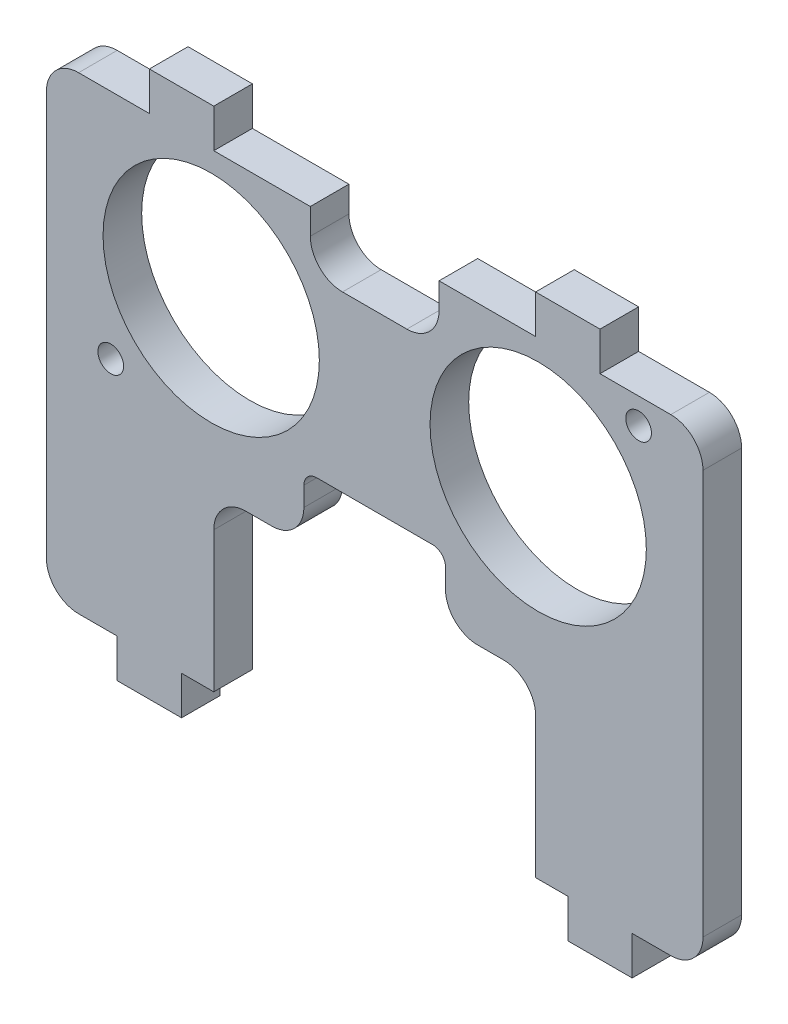
from build123d import *

# Parameters (mm, degrees)
SKETCH1_R           = 1
SKETCH1_R_2         = 8.4
BOSS_EXTRUDE1_DEPTH = 3
SKETCH2_W           = 7
SKETCH2_H           = 4
BOSS_EXTRUDE2_DEPTH = 3
SKETCH5_W           = 3
SKETCH5_H           = 36.4
BOSS_EXTRUDE3_DEPTH = 3
FILLET2_R           = 2.5
FILLET3_R           = 1


with BuildPart() as part:
    # Sketch1 → Boss-Extrude1 (new body)
    with BuildSketch(Plane.XY):
        with BuildLine():
            Line((-20.667019059, -16.4), (-20.667019059, 20))
            Line((-20.667019059, 20), (-15.667019059, 20))
            Line((-15.667019059, 20), (-15.667019059, 23))
            Line((-15.667019059, 23), (-10.667019059, 23))
            Line((-10.667019059, 23), (-10.667019059, 20))
            Line((-10.667019059, 20), (-3.167019059, 20))
            Line((-3.167019059, 20), (-3.167019059, 15.5))
            Line((-3.167019059, 15.5), (6.832980941, 15.5))
            Line((6.832980941, 15.5), (6.832980941, 20))
            Line((6.832980941, 20), (14.332980941, 20))
            Line((14.332980941, 20), (14.332980941, 23))
            Line((14.332980941, 23), (19.332980941, 23))
            Line((19.332980941, 23), (19.332980941, 20))
            Line((19.332980941, 20), (24.332980941, 20))
            Line((24.332980941, 20), (24.332980941, -16.4))
            Line((24.332980941, -16.4), (21.832980941, -16.4))
            Line((21.832980941, -16.4), (21.832980941, -19.4))
            Line((21.832980941, -19.4), (16.832980941, -19.4))
            Line((16.832980941, -19.4), (16.832980941, -16.4))
            Line((16.832980941, -16.4), (14.332980941, -16.4))
            Line((14.332980941, -16.4), (14.332980941, -1))
            ThreePointArc((14.332980941, -1), (14.040087722, -0.292893219), (13.332980941, 0))
            Line((13.332980941, 0), (7.332980941, 0))
            Line((7.332980941, 0), (7.332980941, 2))
            Line((7.332980941, 2), (-3.667019059, 2))
            Line((-3.667019059, 2), (-3.667019059, 0))
            Line((-3.667019059, 0), (-9.667019059, 0))
            ThreePointArc((-9.667019059, 0), (-10.37412584, -0.292893219), (-10.667019059, -1))
            Line((-10.667019059, -1), (-10.667019059, -16.4))
            Line((-10.667019059, -16.4), (-13.167019059, -16.4))
            Line((-13.167019059, -16.4), (-13.167019059, -19.4))
            Line((-13.167019059, -19.4), (-18.167019059, -19.4))
            Line((-18.167019059, -19.4), (-18.167019059, -16.4))
            Line((-18.167019059, -16.4), (-20.667019059, -16.4))
        make_face()
        with Locations((22.332980941, 18)):
            Circle(SKETCH1_R, mode=Mode.SUBTRACT)
        with Locations((-18.667019059, 2)):
            Circle(SKETCH1_R, mode=Mode.SUBTRACT)
        with Locations((-10.867019059, 10)):
            Circle(SKETCH1_R_2, mode=Mode.SUBTRACT)
        with Locations((14.532980941, 10)):
            Circle(SKETCH1_R_2, mode=Mode.SUBTRACT)
    extrude(amount=BOSS_EXTRUDE1_DEPTH)

    # Sketch2 → Boss-Extrude2 (add)
    with BuildSketch(Plane.XY.offset(3)):
        with Locations((-7.167019059, -1)):
            Rectangle(SKETCH2_W, SKETCH2_H)
        with Locations((10.832980941, -1)):
            Rectangle(SKETCH2_W, SKETCH2_H)
    extrude(amount=-BOSS_EXTRUDE2_DEPTH)

    # Sketch5 → Boss-Extrude3 (add)
    with BuildSketch(Plane(origin=(24.332980941, 0, 0), x_dir=(0, 0, -1), z_dir=(1, 0, 0))):
        with Locations((-1.5, 1.8)):
            Rectangle(SKETCH5_W, SKETCH5_H)
    boss_extrude3 = extrude(amount=BOSS_EXTRUDE3_DEPTH)

    # Mirror1: Boss-Extrude3 across plane
    add(boss_extrude3.mirror(Plane(origin=(1.832980941, 0, 0), x_dir=(0, 0, 1), z_dir=(1, 0, 0))))

    # Fillet2
    fillet2_edges = [part.edges().sort_by_distance(p)[0] for p in [
        (-10.667019059, -3, 1.5),
        (-3.667019059, -3, 1.5),
        (7.332980941, -3, 1.5),
        (14.332980941, -3, 1.5),
        (27.332980941, -16.4, 1.5),
        (27.332980941, 20, 1.5),
        (-23.667019059, 20, 1.5),
        (-23.667019059, -16.4, 1.5),
        (-3.167019059, 15.5, 1.5),
        (6.832980941, 15.5, 1.5),
    ]]
    fillet(fillet2_edges, radius=FILLET2_R)

    # Fillet3
    fillet3_edges = [part.edges().sort_by_distance(p)[0] for p in [
        (7.332980941, 2, 1.5),
        (-3.667019059, 2, 1.5),
    ]]
    fillet(fillet3_edges, radius=FILLET3_R)


solid = part.part
